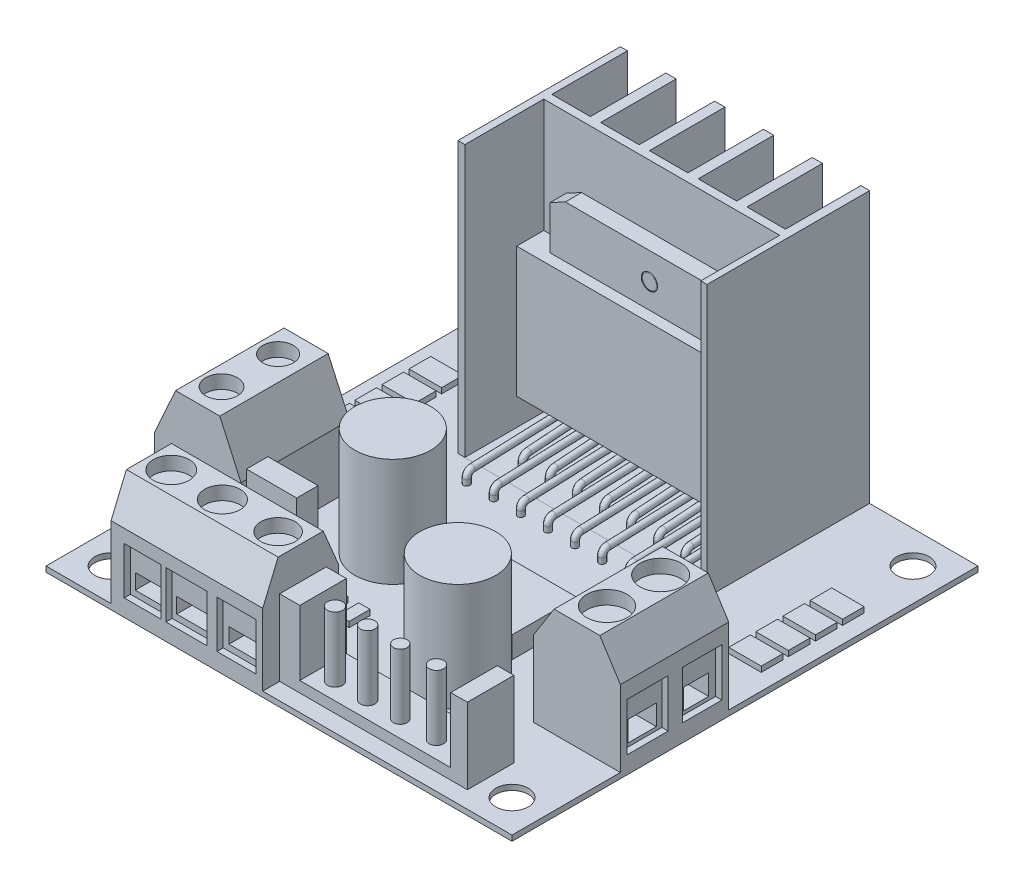
from build123d import *

# Parameters (mm, degrees)
SKETCH1_R                   = 1.5
SKETCH1_W                   = 1.87674342
SKETCH1_H                   = 0.987767776
SKETCH1_W_2                 = 1.047117993
SKETCH1_H_2                 = 1.933140308
SKETCH1_W_3                 = 4.629363757
SKETCH1_H_3                 = 1.975535552
SKETCH1_R_2                 = 3.5
SKETCH1_W_4                 = 6
SKETCH1_H_4                 = 6
SKETCH1_W_5                 = 3
SKETCH1_H_5                 = 2
BOSS_EXTRUDE1_DEPTH         = 0.5
SKETCH1_3_W                 = 23
SKETCH1_3_H                 = 15
BOSS_EXTRUDE2_DEPTH         = 25
BOSS_EXTRUDE2_DEPTH_BACK    = 0.5
SKETCH1_4_W                 = 3
SKETCH1_4_H                 = 2
BOSS_EXTRUDE3_DEPTH         = 0.5
BOSS_EXTRUDE3_DEPTH_BACK    = 0.5
BOSS_EXTRUDE3_2_DEPTH       = 0.5
BOSS_EXTRUDE3_2_DEPTH_BACK  = 0.5
BOSS_EXTRUDE3_3_DEPTH       = 0.5
BOSS_EXTRUDE3_3_DEPTH_BACK  = 0.5
BOSS_EXTRUDE3_4_DEPTH       = 0.5
BOSS_EXTRUDE3_4_DEPTH_BACK  = 0.5
BOSS_EXTRUDE3_5_DEPTH       = 0.5
BOSS_EXTRUDE3_5_DEPTH_BACK  = 0.5
BOSS_EXTRUDE3_6_DEPTH       = 0.5
BOSS_EXTRUDE3_6_DEPTH_BACK  = 0.5
BOSS_EXTRUDE3_7_DEPTH       = 0.5
BOSS_EXTRUDE3_7_DEPTH_BACK  = 0.5
BOSS_EXTRUDE3_8_DEPTH       = 0.5
BOSS_EXTRUDE3_8_DEPTH_BACK  = 0.5
SKETCH1_4_W_2               = 1.87674342
SKETCH1_4_H_2               = 0.987767776
BOSS_EXTRUDE3_9_DEPTH       = 0.5
BOSS_EXTRUDE3_9_DEPTH_BACK  = 0.5
SKETCH1_4_W_3               = 1.047117993
SKETCH1_4_H_3               = 1.933140308
BOSS_EXTRUDE3_10_DEPTH      = 0.5
BOSS_EXTRUDE3_10_DEPTH_BACK = 0.5
SKETCH1_5_R                 = 3.5
BOSS_EXTRUDE4_DEPTH         = 10
BOSS_EXTRUDE4_DEPTH_BACK    = 0.5
SKETCH1_6_W                 = 6
SKETCH1_6_H                 = 6
BOSS_EXTRUDE5_DEPTH         = 2
SKETCH1_7_W                 = 8
SKETCH1_7_H                 = 10
BOSS_EXTRUDE6_DEPTH         = 10
BOSS_EXTRUDE6_DEPTH_BACK    = 0.5
SKETCH1_8_W                 = 4.629363757
SKETCH1_8_H                 = 1.975535552
SKETCH1_8_W_2               = 17.323100011
SKETCH1_8_H_2               = 4.298694917
BOSS_EXTRUDE7_DEPTH         = 7
BOSS_EXTRUDE7_DEPTH_BACK    = 0.5
SKETCH3_W                   = 21.77
SKETCH3_H                   = 7.281510675
SKETCH3_W_2                 = 3.55
SKETCH3_H_2                 = 6.968489325
CUT_EXTRUDE1_DEPTH          = 25
SKETCH4_W                   = 21.822211109
SKETCH4_H                   = 12
BOSS_EXTRUDE8_DEPTH         = 2.5
SKETCH4_4_R                 = 0.75
BOSS_EXTRUDE9_DEPTH         = 1.5
FILLET1_R                   = 0.1
SKETCH6_R                   = 0.3
LPATTERN1_COUNT             = 8
LPATTERN1_PITCH             = 2.5
SKETCH5_R                   = 0.3
SKETCH4_5_R                 = 0.75
SKETCH4_5_W                 = 15.556619177
SKETCH4_5_H                 = 0.75
BOSS_EXTRUDE10_DEPTH        = 1.5
LPATTERN3_COUNT             = 8
LPATTERN3_PITCH             = 2.5
CUT_EXTRUDE2_DEPTH          = 14
CUT_EXTRUDE3_DEPTH          = 10
CUT_EXTRUDE4_DEPTH          = 10
SKETCH14_W                  = 3.41974787
SKETCH14_H                  = 4.353350778
SKETCH14_W_2                = 3.775326231
SKETCH14_W_3                = 3.586931724
CUT_EXTRUDE6_DEPTH          = 4
SKETCH14_4_W                = 2.577830683
SKETCH14_4_H                = 1.413175893
SKETCH14_4_W_2              = 2.832001647
SKETCH14_4_W_3              = 2.538676019
CUT_EXTRUDE7_DEPTH          = 8
SKETCH15_W                  = 3.023453724
SKETCH15_H                  = 1.751290135
SKETCH15_W_2                = 2.858237673
SKETCH15_W_3                = 3.998228422
SKETCH15_H_2                = 3.998228422
SKETCH15_W_4                = 3.816490766
CUT_EXTRUDE8_DEPTH          = 1.5
SKETCH15_3_W                = 3.023453724
SKETCH15_3_H                = 1.751290135
SKETCH15_3_W_2              = 2.858237673
CUT_EXTRUDE9_DEPTH          = 3
SKETCH16_W                  = 2.614326261
SKETCH16_H                  = 1.892862173
SKETCH16_W_2                = 2.335219141
SKETCH16_W_3                = 3.796371446
SKETCH16_H_2                = 4.433469185
SKETCH16_W_4                = 3.633009451
CUT_EXTRUDE10_DEPTH         = 4
SKETCH16_3_W                = 2.614326261
SKETCH16_3_H                = 1.892862173
SKETCH16_3_W_2              = 2.335219141
CUT_EXTRUDE11_DEPTH         = 6
SKETCH17_W                  = 13.929053026
SKETCH17_H                  = 4.430880335
SKETCH17_R                  = 0.691969211
SKETCH17_R_2                = 0.664358057
SKETCH17_R_3                = 0.628537192
SKETCH17_R_4                = 0.66230563
CUT_EXTRUDE12_DEPTH         = 6
SKETCH18_R                  = 1.657866538
SKETCH18_R_2                = 1.635373105
SKETCH18_R_3                = 1.587041844
SKETCH18_R_4                = 1.460606867
SKETCH18_R_5                = 1.406099569
SKETCH18_R_6                = 1.895957692
SKETCH18_R_7                = 1.86639443
CUT_EXTRUDE13_DEPTH         = 1.25


with BuildPart() as part:
    # Sketch1 → Boss-Extrude1 (new body)
    with BuildSketch(Plane(origin=(0, 0, 0), x_dir=(1, 0, 0), z_dir=(0, 1, 0))):
        Polygon((21.780262734, 9.055650914), (21.780262734, 32.055650914), (11.780262734, 32.055650914), (11.780262734, 17.055650914), (-11.219737266, 17.055650914), (-11.219737266, 32.055650914), (-21.219737266, 32.055650914), (-21.219737266, 9.055650914), (-13.219737266, 9.055650914), (-13.219737266, -0.944349086), (-21.219737266, -0.944349086), (-21.219737266, -10.944349086), (-15.219737266, -10.944349086), (-15.219737266, -3.944349086), (-1.219737266, -3.944349086), (-1.219737266, -5.086187069), (16.103362745, -5.086187069), (16.103362745, -9.384881986), (-1.219737266, -9.384881986), (-1.219737266, -10.944349086), (21.780262734, -10.944349086), (21.780262734, -0.944349086), (13.780262734, -0.944349086), (13.780262734, 9.055650914), align=None)
        with Locations((-18.219737266, -7.944349086)):
            Circle(SKETCH1_R, mode=Mode.SUBTRACT)
        with Locations((-5.281365556, -0.450465198)):
            Rectangle(SKETCH1_W, SKETCH1_H, mode=Mode.SUBTRACT)
        with Locations((-2.827428331, -0.923151464)):
            Rectangle(SKETCH1_W_2, SKETCH1_H_2, mode=Mode.SUBTRACT)
        with Locations((-10.405255909, 0.04341869)):
            Rectangle(SKETCH1_W_3, SKETCH1_H_3, mode=Mode.SUBTRACT)
        with Locations((-6.219737266, 6.055650914)):
            Circle(SKETCH1_R_2, mode=Mode.SUBTRACT)
        with Locations((6.780262734, -0.944349086)):
            Circle(SKETCH1_R_2, mode=Mode.SUBTRACT)
        with Locations((18.780262734, -7.944349086)):
            Circle(SKETCH1_R, mode=Mode.SUBTRACT)
        with Locations((4.780262734, 6.055650914)):
            Rectangle(SKETCH1_W_4, SKETCH1_H_4, mode=Mode.SUBTRACT)
        with Locations((-18.219737266, 14.555650914)):
            Rectangle(SKETCH1_W_5, SKETCH1_H_5, mode=Mode.SUBTRACT)
        with Locations((-18.219737266, 17.055650914)):
            Rectangle(SKETCH1_W_5, SKETCH1_H_5, mode=Mode.SUBTRACT)
        with Locations((-18.219737266, 19.555650914)):
            Rectangle(SKETCH1_W_5, SKETCH1_H_5, mode=Mode.SUBTRACT)
        with Locations((-18.219737266, 22.055650914)):
            Rectangle(SKETCH1_W_5, SKETCH1_H_5, mode=Mode.SUBTRACT)
        with Locations((-18.219737266, 29.055650914)):
            Circle(SKETCH1_R, mode=Mode.SUBTRACT)
        with Locations((18.780262734, 14.555650914)):
            Rectangle(SKETCH1_W_5, SKETCH1_H_5, mode=Mode.SUBTRACT)
        with Locations((18.780262734, 17.055650914)):
            Rectangle(SKETCH1_W_5, SKETCH1_H_5, mode=Mode.SUBTRACT)
        with Locations((18.780262734, 19.555650914)):
            Rectangle(SKETCH1_W_5, SKETCH1_H_5, mode=Mode.SUBTRACT)
        with Locations((18.780262734, 22.055650914)):
            Rectangle(SKETCH1_W_5, SKETCH1_H_5, mode=Mode.SUBTRACT)
        with Locations((18.780262734, 29.055650914)):
            Circle(SKETCH1_R, mode=Mode.SUBTRACT)
    extrude(amount=-BOSS_EXTRUDE1_DEPTH)

    # Sketch1_5 → Boss-Extrude4 (add, two sides)
    with BuildSketch(Plane(origin=(0, 0, 0), x_dir=(1, 0, 0), z_dir=(0, 1, 0))) as boss_extrude4_sk:
        with Locations((-6.219737266, 6.055650914)):
            Circle(SKETCH1_5_R)
        with Locations((6.780262734, -0.944349086)):
            Circle(SKETCH1_5_R)
    extrude(amount=BOSS_EXTRUDE4_DEPTH)
    extrude(boss_extrude4_sk.sketch, amount=-BOSS_EXTRUDE4_DEPTH_BACK)

    # Sketch1_7 → Boss-Extrude6 (add, two sides)
    with BuildSketch(Plane(origin=(0, 0, 0), x_dir=(1, 0, 0), z_dir=(0, 1, 0))) as boss_extrude6_sk:
        with Locations((-17.219737266, 4.055650914)):
            Rectangle(SKETCH1_7_W, SKETCH1_7_H)
        with Locations((17.780262734, 4.055650914)):
            Rectangle(SKETCH1_7_W, SKETCH1_7_H)
        Polygon((-15.219737266, -10.944349086), (-1.219737266, -10.944349086), (-1.219737266, -9.384881986), (-1.219737266, -5.086187069), (-1.219737266, -3.944349086), (-15.219737266, -3.944349086), align=None)
    extrude(amount=BOSS_EXTRUDE6_DEPTH)
    extrude(boss_extrude6_sk.sketch, amount=-BOSS_EXTRUDE6_DEPTH_BACK)

    # Sketch1_8 → Boss-Extrude7 (add, two sides)
    with BuildSketch(Plane(origin=(0, 0, 0), x_dir=(1, 0, 0), z_dir=(0, 1, 0))) as boss_extrude7_sk:
        with Locations((-10.405255909, 0.04341869)):
            Rectangle(SKETCH1_8_W, SKETCH1_8_H)
        with Locations((7.44181274, -7.235534528)):
            Rectangle(SKETCH1_8_W_2, SKETCH1_8_H_2)
    extrude(amount=BOSS_EXTRUDE7_DEPTH)
    extrude(boss_extrude7_sk.sketch, amount=-BOSS_EXTRUDE7_DEPTH_BACK)

    # Sketch10 → Cut-Extrude2 (cut)
    with BuildSketch(Plane.ZY.offset(15.219737266)):
        Polygon((5.364896266, 10), (3.944349086, 6.621466278), (3.944349086, 10), align=None)
        Polygon((9.523801907, 10), (10.944349086, 6.621466278), (10.944349086, 10), align=None)
    extrude(amount=-CUT_EXTRUDE2_DEPTH, mode=Mode.SUBTRACT)

    # Sketch12 → Cut-Extrude3 (cut)
    with BuildSketch(Plane.XY.offset(0.944349086)):
        Polygon((-21.219737266, 5.653655285), (-19.257613594, 10), (-21.219737266, 10), align=None)
        Polygon((-13.219737266, 10), (-13.219737266, 5.653655285), (-15.181860939, 10), align=None)
    extrude(amount=-CUT_EXTRUDE3_DEPTH, mode=Mode.SUBTRACT)

    # Sketch13 → Cut-Extrude4 (cut)
    with BuildSketch(Plane.XY.offset(0.944349086)):
        Polygon((19.890577675, 10), (21.780262734, 7.02358264), (21.780262734, 10), align=None)
        Polygon((13.780262734, 10), (15.669947792, 10), (13.780262734, 7.02358264), align=None)
    extrude(amount=-CUT_EXTRUDE4_DEPTH, mode=Mode.SUBTRACT)

    # Sketch14 → Cut-Extrude6 (cut)
    with BuildSketch(Plane.XY.offset(14.364349086)):
        with Locations((-12.297230548, 3.232786989)):
            Rectangle(SKETCH14_W, SKETCH14_H)
        with Locations((-8.262973542, 3.232786989)):
            Rectangle(SKETCH14_W_2, SKETCH14_H)
        with Locations((-3.654087822, 3.232786989)):
            Rectangle(SKETCH14_W_3, SKETCH14_H)
    extrude(amount=-CUT_EXTRUDE6_DEPTH, mode=Mode.SUBTRACT)

    # Sketch14_4 → Cut-Extrude7 (cut)
    with BuildSketch(Plane.XY.offset(14.364349086)):
        with Locations((-12.27107568, 2.314797916)):
            Rectangle(SKETCH14_4_W, SKETCH14_4_H)
        with Locations((-8.32290457, 2.314797916)):
            Rectangle(SKETCH14_4_W_2, SKETCH14_4_H)
        with Locations((-3.651315733, 2.314797916)):
            Rectangle(SKETCH14_4_W_3, SKETCH14_4_H)
    extrude(amount=-CUT_EXTRUDE7_DEPTH, mode=Mode.SUBTRACT)

    # Sketch15 → Cut-Extrude8 (cut)
    with BuildSketch(Plane.ZY.offset(21.219737266)):
        with Locations((-6.567313179, 1.634198747)):
            Rectangle(SKETCH15_W, SKETCH15_H)
        with Locations((-1.544745244, 1.634198747)):
            Rectangle(SKETCH15_W_2, SKETCH15_H)
        with Locations((-6.608617191, 2.509843814)):
            Rectangle(SKETCH15_W_3, SKETCH15_H_2)
        with Locations((-6.567313179, 1.634198747)):
            Rectangle(SKETCH15_W, SKETCH15_H, mode=Mode.SUBTRACT)
        with Locations((-1.627353269, 2.509843814)):
            Rectangle(SKETCH15_W_4, SKETCH15_H_2)
        with Locations((-1.544745244, 1.634198747)):
            Rectangle(SKETCH15_W_2, SKETCH15_H, mode=Mode.SUBTRACT)
    extrude(amount=-CUT_EXTRUDE8_DEPTH, mode=Mode.SUBTRACT)

    # Sketch15_3 → Cut-Extrude9 (cut)
    with BuildSketch(Plane.ZY.offset(21.219737266)):
        with Locations((-6.567313179, 1.634198747)):
            Rectangle(SKETCH15_3_W, SKETCH15_3_H)
        with Locations((-1.544745244, 1.634198747)):
            Rectangle(SKETCH15_3_W_2, SKETCH15_3_H)
    extrude(amount=-CUT_EXTRUDE9_DEPTH, mode=Mode.SUBTRACT)

    # Sketch16 → Cut-Extrude10 (cut)
    with BuildSketch(Plane(origin=(25.200262734, 0, 0), x_dir=(0, 0, -1), z_dir=(1, 0, 0))):
        with Locations((1.649660692, 2.37301006)):
            Rectangle(SKETCH16_W, SKETCH16_H)
        with Locations((6.617436093, 2.37301006)):
            Rectangle(SKETCH16_W_2, SKETCH16_H)
        with Locations((1.57237227, 3.319441148)):
            Rectangle(SKETCH16_W_3, SKETCH16_H_2)
        with Locations((1.649660692, 2.37301006)):
            Rectangle(SKETCH16_W, SKETCH16_H, mode=Mode.SUBTRACT)
        with Locations((6.603635893, 3.319441148)):
            Rectangle(SKETCH16_W_4, SKETCH16_H_2)
        with Locations((6.617436093, 2.37301006)):
            Rectangle(SKETCH16_W_2, SKETCH16_H, mode=Mode.SUBTRACT)
    extrude(amount=-CUT_EXTRUDE10_DEPTH, mode=Mode.SUBTRACT)

    # Sketch16_3 → Cut-Extrude11 (cut)
    with BuildSketch(Plane(origin=(25.200262734, 0, 0), x_dir=(0, 0, -1), z_dir=(1, 0, 0))):
        with Locations((1.649660692, 2.37301006)):
            Rectangle(SKETCH16_3_W, SKETCH16_3_H)
        with Locations((6.617436093, 2.37301006)):
            Rectangle(SKETCH16_3_W_2, SKETCH16_3_H)
    extrude(amount=-CUT_EXTRUDE11_DEPTH, mode=Mode.SUBTRACT)

    # Sketch17 → Cut-Extrude12 (cut)
    with BuildSketch(Plane(origin=(0, 7, 0), x_dir=(1, 0, 0), z_dir=(0, 1, 0))):
        with Locations((7.601473887, -7.301627236)):
            Rectangle(SKETCH17_W, SKETCH17_H)
        with Locations((2.31010845, -7.805187753)):
            Circle(SKETCH17_R, mode=Mode.SUBTRACT)
        with Locations((5.321463737, -7.805187753)):
            Circle(SKETCH17_R_2, mode=Mode.SUBTRACT)
        with Locations((8.334078171, -7.805187753)):
            Circle(SKETCH17_R_3, mode=Mode.SUBTRACT)
        with Locations((11.67100182, -7.805187753)):
            Circle(SKETCH17_R_4, mode=Mode.SUBTRACT)
    extrude(amount=-CUT_EXTRUDE12_DEPTH, mode=Mode.SUBTRACT)

    # Sketch18 → Cut-Extrude13 (cut)
    with BuildSketch(Plane(origin=(0, 10, 0), x_dir=(1, 0, 0), z_dir=(0, 1, 0))):
        with Locations((-13.118368013, -7.489992052)):
            Circle(SKETCH18_R)
        with Locations((-8.398682935, -7.489992052)):
            Circle(SKETCH18_R_2)
        with Locations((-3.260725332, -7.489992052)):
            Circle(SKETCH18_R_3)
        with Locations((-17.447225534, 1.478648189)):
            Circle(SKETCH18_R_4)
        with Locations((-17.447225534, 6.696831679)):
            Circle(SKETCH18_R_5)
        with Locations((17.857868971, 6.696831679)):
            Circle(SKETCH18_R_6)
        with Locations((17.857868971, 1.743546675)):
            Circle(SKETCH18_R_7)
    extrude(amount=-CUT_EXTRUDE13_DEPTH, mode=Mode.SUBTRACT)


with BuildPart() as body_2:
    # Sketch1_3 → Boss-Extrude2 (new body, two sides)
    with BuildSketch(Plane(origin=(0, 0, 0), x_dir=(1, 0, 0), z_dir=(0, 1, 0))) as boss_extrude2_sk:
        with Locations((0.280262734, 24.555650914)):
            Rectangle(SKETCH1_3_W, SKETCH1_3_H)
    extrude(amount=BOSS_EXTRUDE2_DEPTH)
    extrude(boss_extrude2_sk.sketch, amount=-BOSS_EXTRUDE2_DEPTH_BACK)

    # Sketch3 → Cut-Extrude1 (cut)
    with BuildSketch(Plane(origin=(0, 25, 0), x_dir=(1, 0, 0), z_dir=(0, 1, 0))):
        with Locations((0.315262734, 20.696406252)):
            Rectangle(SKETCH3_W, SKETCH3_H)
        with Locations((-8.794737266, 28.571406252)):
            Rectangle(SKETCH3_W_2, SKETCH3_H_2)
        with Locations((-4.294737266, 28.571406252)):
            Rectangle(SKETCH3_W_2, SKETCH3_H_2)
        with Locations((0.205262734, 28.571406252)):
            Rectangle(SKETCH3_W_2, SKETCH3_H_2)
        with Locations((4.705262734, 28.571406252)):
            Rectangle(SKETCH3_W_2, SKETCH3_H_2)
        with Locations((9.205262734, 28.571406252)):
            Rectangle(SKETCH3_W_2, SKETCH3_H_2)
    extrude(amount=-CUT_EXTRUDE1_DEPTH, mode=Mode.SUBTRACT)

    # Sketch4 → Boss-Extrude8 (add)
    with BuildSketch(Plane.XY.offset(-24.337161589)):
        with Locations((0.28915718, 8.5)):
            Rectangle(SKETCH4_W, SKETCH4_H)
    extrude(amount=BOSS_EXTRUDE8_DEPTH)

    # Sketch4_4 → Boss-Extrude9 (add)
    with BuildSketch(Plane.XY.offset(-24.337161589)):
        with Locations((0.681821006, 16.777489386)):
            Circle(SKETCH4_4_R)
    extrude(amount=BOSS_EXTRUDE9_DEPTH)

    # Fillet1
    fillet1_edges = [body_2.edges().sort_by_distance(p)[0] for p in [
        (-0.068178994, 16.777489386, -22.837161589),
    ]]
    fillet(fillet1_edges, radius=FILLET1_R)

    # Sweep8: sweep along a path in Sketch7
    with BuildLine(Plane(origin=(-8.399737266, 0, 0), x_dir=(0, 0, -1), z_dir=(1, 0, 0))) as sweep8_path:
        Line((15.055650914, 0), (15.055650914, 0.501421112))
        ThreePointArc((15.055650914, 0.501421112), (15.195620266, 0.848376345), (15.537162646, 1.00107918))
        Line((15.537162646, 1.00107918), (24.345631529, 1.327008729))
    # Sketch6 → Sweep8 (sweep)
    with BuildSketch(Plane(origin=(0, 0, 0), x_dir=(1, 0, 0), z_dir=(0, 1, 0))):
        with Locations((-8.399737266, 15.055650914)):
            Circle(SKETCH6_R)
    sweep8 = sweep(path=sweep8_path.line)

    # LPattern1: Sweep8 ×8
    with Locations(*[(i * LPATTERN1_PITCH, 0, 0) for i in range(1, LPATTERN1_COUNT)]):
        add(sweep8)

    # Sweep9: sweep along a path in Sketch8
    with BuildLine(Plane(origin=(-7.149737266, 0, 0), x_dir=(0, 0, -1), z_dir=(1, 0, 0))) as sweep9_path:
        Line((19.000368719, 0), (19.000368719, 0.432850988))
        ThreePointArc((19.000368719, 0.432850988), (19.134446652, 0.773587017), (19.464772885, 0.931582315))
        Line((19.464772885, 0.931582315), (24.395270233, 1.283485545))
    # Sketch5 → Sweep9 (sweep)
    with BuildSketch(Plane.XY.offset(-24.337161589)):
        with Locations((-7.146603085, 1.311245351)):
            Circle(SKETCH5_R)
    sweep9 = sweep(path=sweep9_path.line)

    # Sketch4_5 → Boss-Extrude10 (add)
    with BuildSketch(Plane.XY.offset(-24.337161589)):
        Polygon((-8.485442602, 14.5), (9.681821006, 14.5), (9.681821006, 18.522120271), (8.475876315, 18.522120271), (-7.080742862, 18.522120271), (-8.485442602, 18.522120271), align=None)
        with Locations((0.681821006, 16.777489386)):
            Circle(SKETCH4_5_R, mode=Mode.SUBTRACT)
        with Locations((0.697566727, 18.897120271)):
            Rectangle(SKETCH4_5_W, SKETCH4_5_H)
        Polygon((-7.080742862, 19.272120271), (-8.485442602, 18.522120271), (-7.080742862, 18.522120271), align=None)
        Polygon((8.475876315, 18.522120271), (9.681821006, 18.522120271), (8.475876315, 19.272120271), align=None)
    extrude(amount=BOSS_EXTRUDE10_DEPTH)

    # LPattern3: Sweep9 ×8
    with Locations(*[(i * LPATTERN3_PITCH, 0, 0) for i in range(1, LPATTERN3_COUNT)]):
        add(sweep9)


with BuildPart() as body_3:
    # Sketch1_4 → Boss-Extrude3 (new body, two sides)
    with BuildSketch(Plane(origin=(0, 0, 0), x_dir=(1, 0, 0), z_dir=(0, 1, 0))) as boss_extrude3_sk:
        with Locations((18.780262734, 22.055650914)):
            Rectangle(SKETCH1_4_W, SKETCH1_4_H)
    extrude(amount=BOSS_EXTRUDE3_DEPTH)
    extrude(boss_extrude3_sk.sketch, amount=-BOSS_EXTRUDE3_DEPTH_BACK)


with BuildPart() as body_4:
    # Sketch1_4 → Boss-Extrude3 2 (new body, two sides)
    with BuildSketch(Plane(origin=(0, 0, 0), x_dir=(1, 0, 0), z_dir=(0, 1, 0))) as boss_extrude3_2_sk:
        with Locations((18.780262734, 19.555650914)):
            Rectangle(SKETCH1_4_W, SKETCH1_4_H)
    extrude(amount=BOSS_EXTRUDE3_2_DEPTH)
    extrude(boss_extrude3_2_sk.sketch, amount=-BOSS_EXTRUDE3_2_DEPTH_BACK)


with BuildPart() as body_5:
    # Sketch1_4 → Boss-Extrude3 3 (new body, two sides)
    with BuildSketch(Plane(origin=(0, 0, 0), x_dir=(1, 0, 0), z_dir=(0, 1, 0))) as boss_extrude3_3_sk:
        with Locations((18.780262734, 17.055650914)):
            Rectangle(SKETCH1_4_W, SKETCH1_4_H)
    extrude(amount=BOSS_EXTRUDE3_3_DEPTH)
    extrude(boss_extrude3_3_sk.sketch, amount=-BOSS_EXTRUDE3_3_DEPTH_BACK)


with BuildPart() as body_6:
    # Sketch1_4 → Boss-Extrude3 4 (new body, two sides)
    with BuildSketch(Plane(origin=(0, 0, 0), x_dir=(1, 0, 0), z_dir=(0, 1, 0))) as boss_extrude3_4_sk:
        with Locations((18.780262734, 14.555650914)):
            Rectangle(SKETCH1_4_W, SKETCH1_4_H)
    extrude(amount=BOSS_EXTRUDE3_4_DEPTH)
    extrude(boss_extrude3_4_sk.sketch, amount=-BOSS_EXTRUDE3_4_DEPTH_BACK)


with BuildPart() as body_7:
    # Sketch1_4 → Boss-Extrude3 5 (new body, two sides)
    with BuildSketch(Plane(origin=(0, 0, 0), x_dir=(1, 0, 0), z_dir=(0, 1, 0))) as boss_extrude3_5_sk:
        with Locations((-18.219737266, 22.055650914)):
            Rectangle(SKETCH1_4_W, SKETCH1_4_H)
    extrude(amount=BOSS_EXTRUDE3_5_DEPTH)
    extrude(boss_extrude3_5_sk.sketch, amount=-BOSS_EXTRUDE3_5_DEPTH_BACK)


with BuildPart() as body_8:
    # Sketch1_4 → Boss-Extrude3 6 (new body, two sides)
    with BuildSketch(Plane(origin=(0, 0, 0), x_dir=(1, 0, 0), z_dir=(0, 1, 0))) as boss_extrude3_6_sk:
        with Locations((-18.219737266, 19.555650914)):
            Rectangle(SKETCH1_4_W, SKETCH1_4_H)
    extrude(amount=BOSS_EXTRUDE3_6_DEPTH)
    extrude(boss_extrude3_6_sk.sketch, amount=-BOSS_EXTRUDE3_6_DEPTH_BACK)


with BuildPart() as body_9:
    # Sketch1_4 → Boss-Extrude3 7 (new body, two sides)
    with BuildSketch(Plane(origin=(0, 0, 0), x_dir=(1, 0, 0), z_dir=(0, 1, 0))) as boss_extrude3_7_sk:
        with Locations((-18.219737266, 17.055650914)):
            Rectangle(SKETCH1_4_W, SKETCH1_4_H)
    extrude(amount=BOSS_EXTRUDE3_7_DEPTH)
    extrude(boss_extrude3_7_sk.sketch, amount=-BOSS_EXTRUDE3_7_DEPTH_BACK)


with BuildPart() as body_10:
    # Sketch1_4 → Boss-Extrude3 8 (new body, two sides)
    with BuildSketch(Plane(origin=(0, 0, 0), x_dir=(1, 0, 0), z_dir=(0, 1, 0))) as boss_extrude3_8_sk:
        with Locations((-18.219737266, 14.555650914)):
            Rectangle(SKETCH1_4_W, SKETCH1_4_H)
    extrude(amount=BOSS_EXTRUDE3_8_DEPTH)
    extrude(boss_extrude3_8_sk.sketch, amount=-BOSS_EXTRUDE3_8_DEPTH_BACK)


with BuildPart() as body_11:
    # Sketch1_4 → Boss-Extrude3 9 (new body, two sides)
    with BuildSketch(Plane(origin=(0, 0, 0), x_dir=(1, 0, 0), z_dir=(0, 1, 0))) as boss_extrude3_9_sk:
        with Locations((-5.281365556, -0.450465198)):
            Rectangle(SKETCH1_4_W_2, SKETCH1_4_H_2)
    extrude(amount=BOSS_EXTRUDE3_9_DEPTH)
    extrude(boss_extrude3_9_sk.sketch, amount=-BOSS_EXTRUDE3_9_DEPTH_BACK)


with BuildPart() as body_12:
    # Sketch1_4 → Boss-Extrude3 10 (new body, two sides)
    with BuildSketch(Plane(origin=(0, 0, 0), x_dir=(1, 0, 0), z_dir=(0, 1, 0))) as boss_extrude3_10_sk:
        with Locations((-2.827428331, -0.923151464)):
            Rectangle(SKETCH1_4_W_3, SKETCH1_4_H_3)
    extrude(amount=BOSS_EXTRUDE3_10_DEPTH)
    extrude(boss_extrude3_10_sk.sketch, amount=-BOSS_EXTRUDE3_10_DEPTH_BACK)


with BuildPart() as body_13:
    # Sketch1_6 → Boss-Extrude5 (new body)
    with BuildSketch(Plane(origin=(0, 0, 0), x_dir=(1, 0, 0), z_dir=(0, 1, 0))):
        with Locations((4.780262734, 6.055650914)):
            Rectangle(SKETCH1_6_W, SKETCH1_6_H)
    extrude(amount=BOSS_EXTRUDE5_DEPTH)


solid = Compound([part.part, body_2.part, body_3.part, body_4.part, body_5.part, body_6.part, body_7.part, body_8.part, body_9.part, body_10.part, body_11.part, body_12.part, body_13.part])
